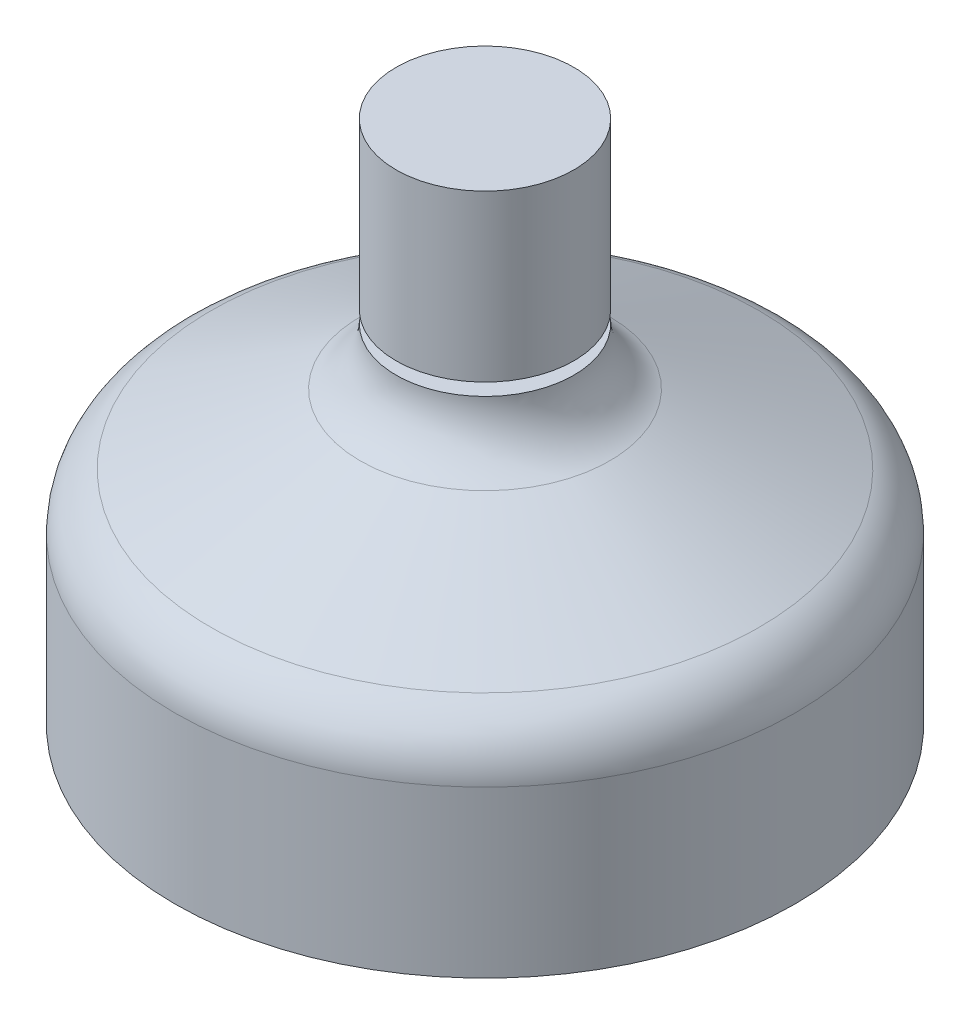
from build123d import *

# Parameters (mm, degrees)
SKETCH2_R           = 1.075
BOSS_EXTRUDE2_DEPTH = 2


with BuildPart() as part:
    # Sketch6 → Revolve-Thin2 (revolve)
    with BuildSketch(Plane(origin=(0, 0, 0), x_dir=(0, 0, -1), z_dir=(1, 0, 0))):
        with BuildLine():
            Line((-3.75, 0), (-3.75, 2))
            ThreePointArc((-3.75, 2), (-3.632270634, 2.403402832), (-3.31604308, 2.680159372))
            Line((-3.31604308, 2.680159372), (-1.50895692, 3.519840628))
            ThreePointArc((-1.50895692, 3.519840628), (-1.192729366, 3.796597168), (-1.075, 4.2))
            Line((-1.075, 4.2), (-0.575, 4.2))
            ThreePointArc((-0.575, 4.2), (-0.77121561, 3.527661946), (-1.298261533, 3.066401046))
            Line((-1.298261533, 3.066401046), (-3.105347693, 2.226719791))
            ThreePointArc((-3.105347693, 2.226719791), (-3.210756878, 2.134467611), (-3.25, 2))
            Line((-3.25, 2), (-3.25, 0))
            Line((-3.25, 0), (-3.75, 0))
        make_face()
    revolve(axis=Axis((0, -0.227579974, 0), (0, 1, 0)))


with BuildPart() as body_2:
    # Sketch2 → Boss-Extrude2 (new body)
    with BuildSketch(Plane(origin=(0, 6.35, 0), x_dir=(1, 0, 0), z_dir=(0, 1, 0))):
        Circle(SKETCH2_R)
    extrude(amount=-BOSS_EXTRUDE2_DEPTH)


solid = Compound([part.part, body_2.part])
